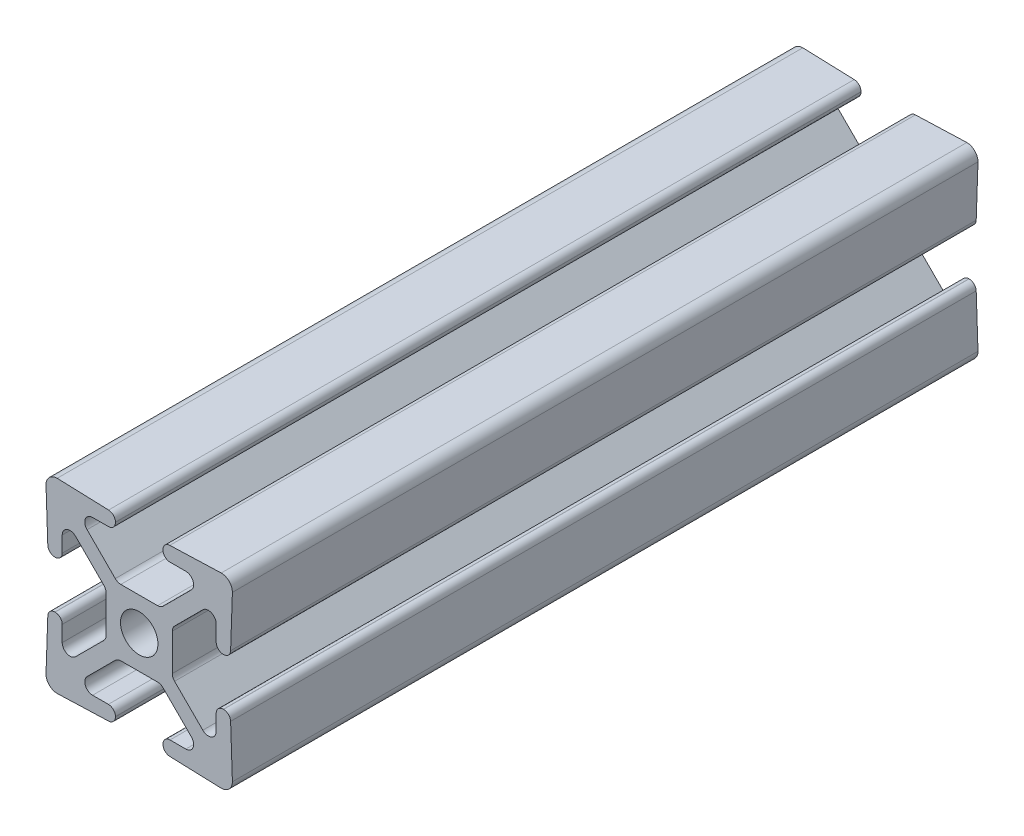
from build123d import *

# Parameters (mm, degrees)
SKETCH1_R      = 2.5527
EXTRUDE1_DEPTH = 101.6


with BuildPart() as part:
    # Sketch1 → Extrude1 (new body)
    with BuildSketch(Plane.XY):
        with BuildLine():
            Line((3.238504286, -11.455400345), (3.238504286, -11.49073383))
            ThreePointArc((3.238504286, -11.49073383), (3.509397472, -12.161218003), (4.170019162, -12.455345741))
            Line((4.170019162, -12.455345741), (11.176001705, -12.7))
            ThreePointArc((11.176001705, -12.7), (12.253632411, -12.253630746), (12.700001664, -11.17600004))
            Line((12.700001664, -11.17600004), (12.455347406, -4.170014669))
            ThreePointArc((12.455347406, -4.170014669), (12.16121968, -3.509392954), (11.490735494, -3.238499755))
            Line((11.490735494, -3.238499755), (11.455402009, -3.238499755))
            ThreePointArc((11.455402009, -3.238499755), (10.772902626, -3.521200256), (10.490202125, -4.20369964))
            Line((10.490202125, -4.20369964), (10.490202125, -6.352134987))
            ThreePointArc((10.490202125, -6.352134987), (9.831646779, -7.337732713), (8.669054992, -7.106478829))
            Line((8.669054992, -7.106478829), (4.820959759, -3.258383596))
            ThreePointArc((4.820959759, -3.258383596), (4.589705874, -2.912287699), (4.508500309, -2.504039754))
            Line((4.508500309, -2.504039754), (4.508500309, 2.504040946))
            ThreePointArc((4.508500309, 2.504040946), (4.589705874, 2.912288891), (4.820959759, 3.258384788))
            Line((4.820959759, 3.258384788), (8.669054992, 7.106480021))
            ThreePointArc((8.669054992, 7.106480021), (9.831646779, 7.337733906), (10.490202125, 6.35213618))
            Line((10.490202125, 6.35213618), (10.490202125, 4.203700832))
            ThreePointArc((10.490202125, 4.203700832), (10.772902626, 3.521201448), (11.455402009, 3.238500947))
            Line((11.455402009, 3.238500947), (11.490735494, 3.238500947))
            ThreePointArc((11.490735494, 3.238500947), (12.161219667, 3.509394133), (12.455347406, 4.170015823))
            Line((12.455347406, 4.170015823), (12.700001664, 11.176000039))
            ThreePointArc((12.700001664, 11.176000039), (12.253632411, 12.253630745), (11.176001705, 12.699999999))
            Line((11.176001705, 12.699999999), (4.170019162, 12.455345462))
            ThreePointArc((4.170019162, 12.455345462), (3.509397447, 12.161217736), (3.238504248, 11.49073355))
            Line((3.238504248, 11.49073355), (3.238504248, 11.455400065))
            ThreePointArc((3.238504248, 11.455400065), (3.521204749, 10.772900682), (4.203704132, 10.490200181))
            Line((4.203704132, 10.490200181), (6.35213948, 10.490200181))
            ThreePointArc((6.35213948, 10.490200181), (7.337737205, 9.831644835), (7.106483322, 8.669053049))
            Line((7.106483322, 8.669053049), (3.258388088, 4.820957816))
            ThreePointArc((3.258388088, 4.820957816), (2.912292192, 4.589703931), (2.504044247, 4.508498366))
            Line((2.504044247, 4.508498366), (-2.504036453, 4.508498366))
            ThreePointArc((-2.504036453, 4.508498366), (-2.912284398, 4.589703931), (-3.258380295, 4.820957816))
            Line((-3.258380295, 4.820957816), (-7.106475528, 8.669053049))
            ThreePointArc((-7.106475528, 8.669053049), (-7.337729412, 9.831644836), (-6.352131686, 10.490200182))
            Line((-6.352131686, 10.490200182), (-4.203696339, 10.490200182))
            ThreePointArc((-4.203696339, 10.490200182), (-3.521196955, 10.772900683), (-3.238496454, 11.455400067))
            Line((-3.238496454, 11.455400067), (-3.238496454, 11.490733551))
            ThreePointArc((-3.238496454, 11.490733551), (-3.50938964, 12.161217724), (-4.17001133, 12.455345462))
            Line((-4.17001133, 12.455345462), (-11.175998375, 12.699999999))
            ThreePointArc((-11.175998375, 12.699999999), (-12.253629081, 12.253630745), (-12.699998335, 11.176000039))
            Line((-12.699998335, 11.176000039), (-12.455343798, 4.170015823))
            ThreePointArc((-12.455343798, 4.170015823), (-12.161216073, 3.509394108), (-11.490731887, 3.238500909))
            Line((-11.490731887, 3.238500909), (-11.455398403, 3.238500909))
            ThreePointArc((-11.455398403, 3.238500909), (-10.772899019, 3.52120141), (-10.490198518, 4.203700793))
            Line((-10.490198518, 4.203700793), (-10.490198518, 6.352136141))
            ThreePointArc((-10.490198518, 6.352136141), (-9.831643172, 7.337733867), (-8.669051385, 7.106479983))
            Line((-8.669051385, 7.106479983), (-4.820956152, 3.258384749))
            ThreePointArc((-4.820956152, 3.258384749), (-4.589702267, 2.912288853), (-4.508496702, 2.504040908))
            Line((-4.508496702, 2.504040908), (-4.508496702, -2.504039793))
            ThreePointArc((-4.508496702, -2.504039793), (-4.589702267, -2.912287738), (-4.820956152, -3.258383634))
            Line((-4.820956152, -3.258383634), (-8.669051385, -7.106478867))
            ThreePointArc((-8.669051385, -7.106478867), (-9.831643172, -7.337732752), (-10.490198518, -6.352135026))
            Line((-10.490198518, -6.352135026), (-10.490198518, -4.203699678))
            ThreePointArc((-10.490198518, -4.203699678), (-10.772899019, -3.521200294), (-11.455398403, -3.238499793))
            Line((-11.455398403, -3.238499793), (-11.490731887, -3.238499793))
            ThreePointArc((-11.490731887, -3.238499793), (-12.16121606, -3.509392979), (-12.455343798, -4.170014669))
            Line((-12.455343798, -4.170014669), (-12.699998335, -11.17600004))
            ThreePointArc((-12.699998335, -11.17600004), (-12.253629081, -12.253630746), (-11.175998375, -12.7))
            Line((-11.175998375, -12.7), (-4.17001133, -12.455345741))
            ThreePointArc((-4.17001133, -12.455345741), (-3.509389615, -12.161218016), (-3.238496416, -11.49073383))
            Line((-3.238496416, -11.49073383), (-3.238496416, -11.455400345))
            ThreePointArc((-3.238496416, -11.455400345), (-3.521196917, -10.772900961), (-4.2036963, -10.49020046))
            Line((-4.2036963, -10.49020046), (-6.352131648, -10.49020046))
            ThreePointArc((-6.352131648, -10.49020046), (-7.337729374, -9.831645114), (-7.106475489, -8.669053328))
            Line((-7.106475489, -8.669053328), (-3.258380256, -4.820958094))
            ThreePointArc((-3.258380256, -4.820958094), (-2.91228436, -4.58970421), (-2.504036415, -4.508498645))
            Line((-2.504036415, -4.508498645), (2.504044285, -4.508498645))
            ThreePointArc((2.504044285, -4.508498645), (2.91229223, -4.58970421), (3.258388127, -4.820958094))
            Line((3.258388127, -4.820958094), (7.10648336, -8.669053328))
            ThreePointArc((7.10648336, -8.669053328), (7.337737245, -9.831645114), (6.352139519, -10.49020046))
            Line((6.352139519, -10.49020046), (4.203704171, -10.49020046))
            ThreePointArc((4.203704171, -10.49020046), (3.521204787, -10.772900961), (3.238504286, -11.455400345))
        make_face()
        Circle(SKETCH1_R, mode=Mode.SUBTRACT)
    extrude(amount=EXTRUDE1_DEPTH)


solid = part.part
